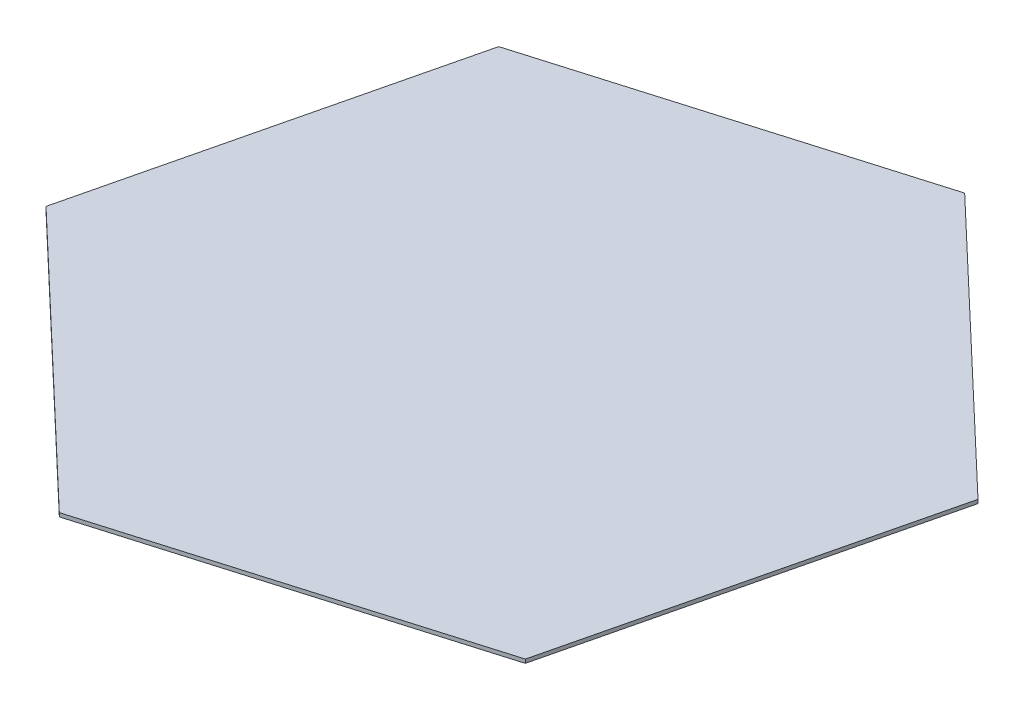
from build123d import *

# Parameters (mm, degrees)
BOSS_EXTRUDE1_DEPTH = 2


with BuildPart() as part:
    # Sketch1 → Boss-Extrude1 (new body)
    with BuildSketch(Plane(origin=(0, 0, 0), x_dir=(1, 0, 0), z_dir=(0, 1, 0))):
        Polygon((-46.893582955, -194.42477177), (144.93, -137.823419998), (191.823582955, 56.601351771), (46.893582955, 194.42477177), (-144.93, 137.823419998), (-191.823582955, -56.601351771), align=None)
    extrude(amount=BOSS_EXTRUDE1_DEPTH)


solid = part.part
